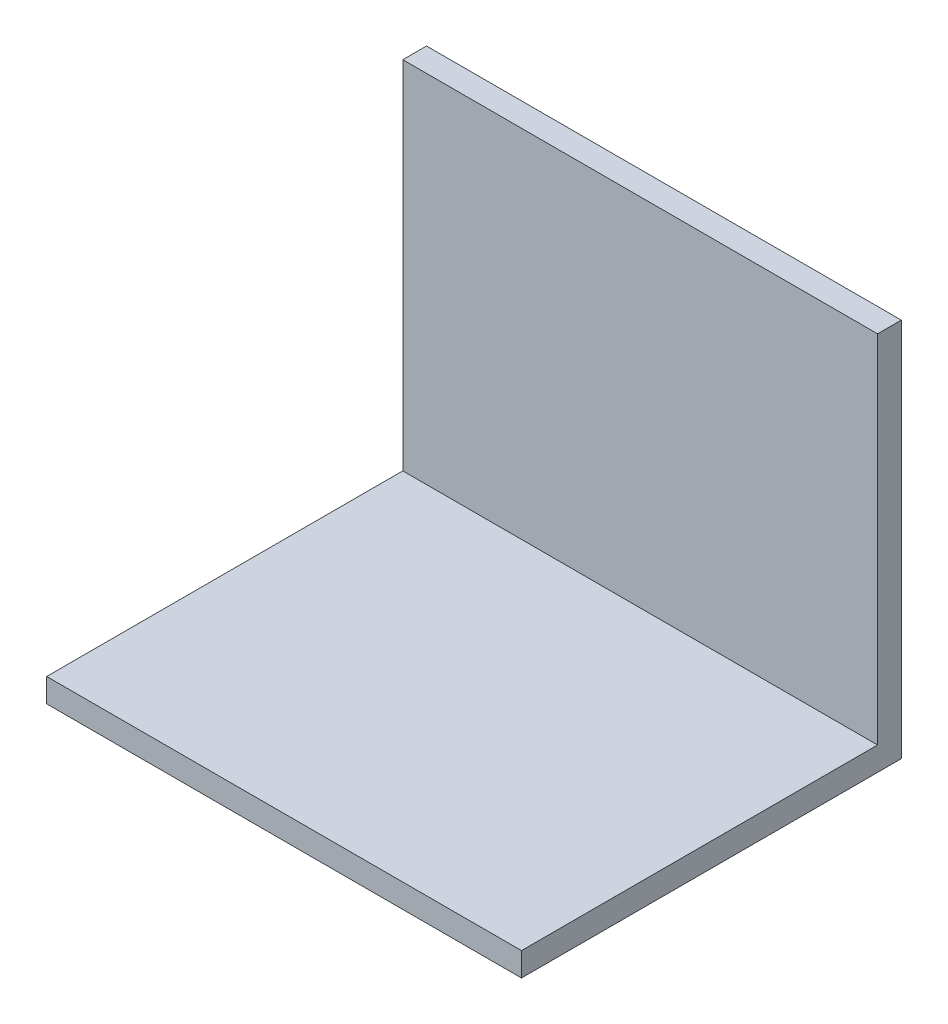
from build123d import *

# Parameters (mm, degrees)
BOSS_EXTRUDE1_DEPTH = 127


with BuildPart() as part:
    # Sketch2 → Boss-Extrude1 (new body)
    with BuildSketch(Plane(origin=(0, 0, 0), x_dir=(0, 0, -1), z_dir=(1, 0, 0))):
        Polygon((0, 0), (-101.6, 0), (-101.6, 6.35), (-6.35, 6.35), (-6.35, 101.6), (0, 101.6), align=None)
    extrude(amount=BOSS_EXTRUDE1_DEPTH)


solid = part.part
